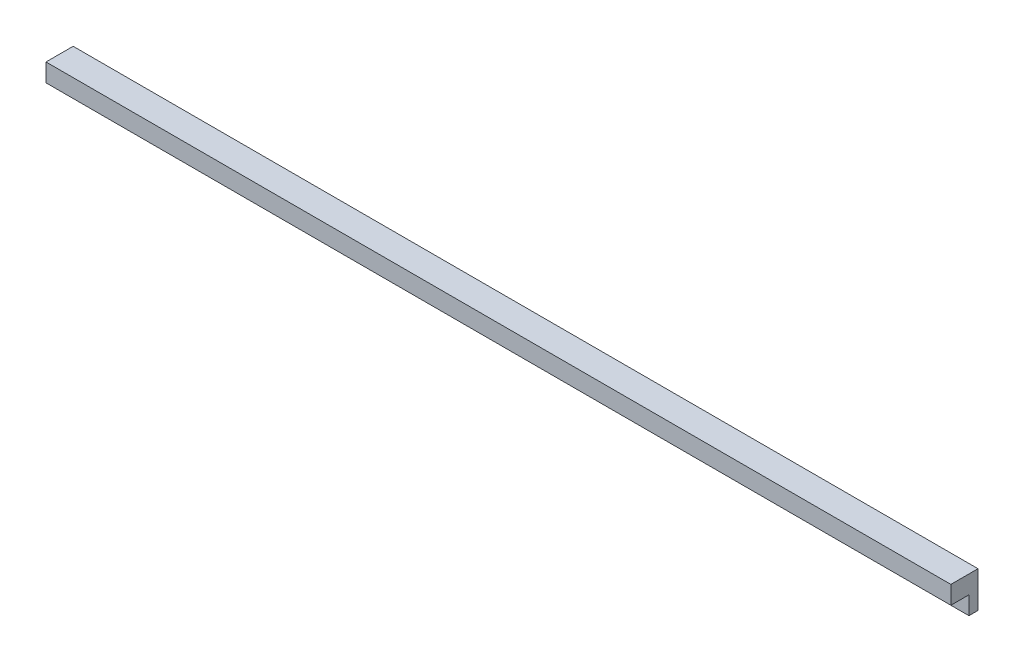
from build123d import *

# Parameters (mm, degrees)
SKETCH2_W           = 500
SKETCH2_H           = 15
BOSS_EXTRUDE3_DEPTH = 10
SKETCH5_W           = 500
SKETCH5_H           = 5
BOSS_EXTRUDE5_DEPTH = 10


with BuildPart() as part:
    # Sketch2 → Boss-Extrude3 (new body)
    with BuildSketch(Plane(origin=(0, 0, 0), x_dir=(1, 0, 0), z_dir=(0, 1, 0))):
        Rectangle(SKETCH2_W, SKETCH2_H)
    extrude(amount=BOSS_EXTRUDE3_DEPTH)

    # Sketch5 → Boss-Extrude5 (add)
    with BuildSketch(Plane(origin=(0, 0, 0), x_dir=(1, 0, 0), z_dir=(0, 1, 0))):
        with Locations((0, 5)):
            Rectangle(SKETCH5_W, SKETCH5_H)
    extrude(amount=-BOSS_EXTRUDE5_DEPTH)


solid = part.part
